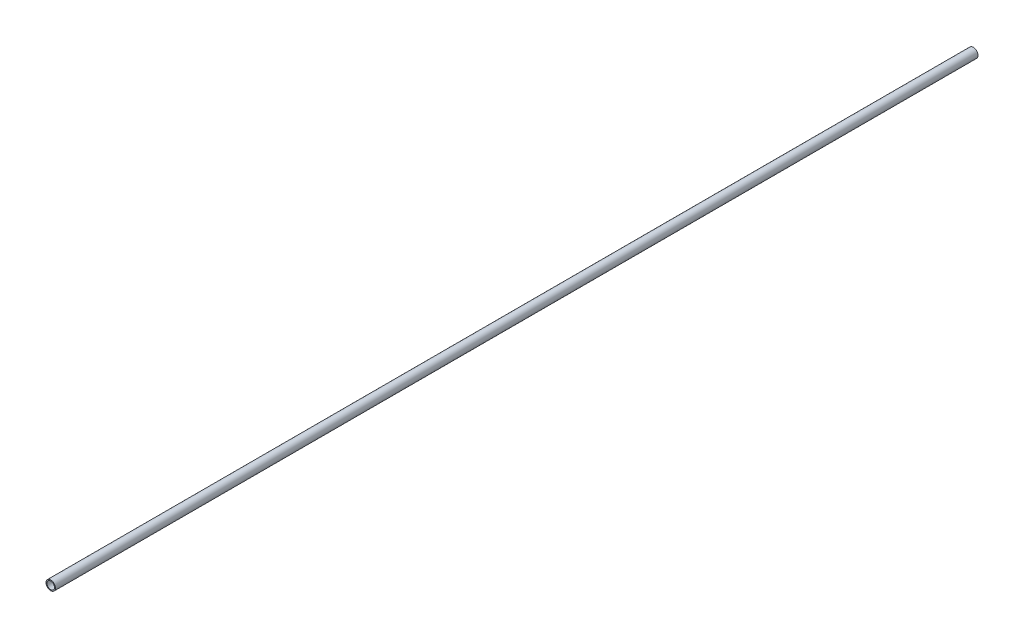
from build123d import *

# Parameters (mm, degrees)
SKETCH1_R           = 6.35
SKETCH1_R_2         = 5.08
BOSS_EXTRUDE1_DEPTH = 1244.6


with BuildPart() as part:
    # Sketch1 → Boss-Extrude1 (new body)
    with BuildSketch(Plane.XY):
        Circle(SKETCH1_R)
        Circle(SKETCH1_R_2, mode=Mode.SUBTRACT)
    extrude(amount=BOSS_EXTRUDE1_DEPTH)


solid = part.part
